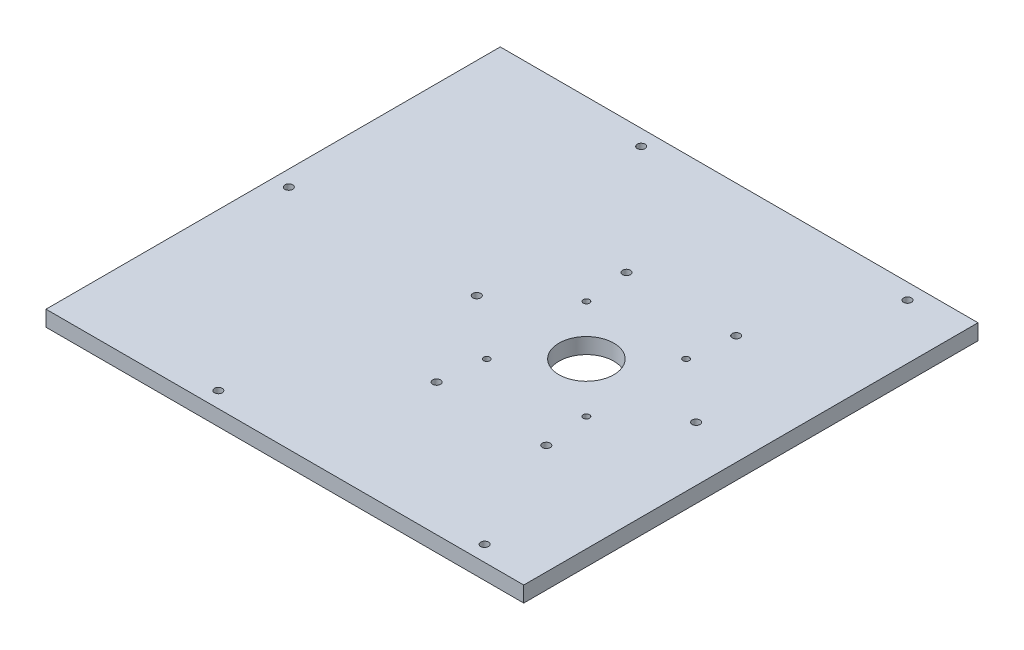
from build123d import *

# Parameters (mm, degrees)
SKETCH1_W           = 305
SKETCH1_H           = 290
SKETCH1_R           = 17.5
SKETCH1_R_2         = 2.5
SKETCH1_R_3         = 2
BOSS_EXTRUDE1_DEPTH = 10


with BuildPart() as part:
    # Sketch1 → Boss-Extrude1 (new body)
    with BuildSketch(Plane(origin=(0, 0, 0), x_dir=(1, 0, 0), z_dir=(0, 1, 0))):
        with Locations((-22.5, 0)):
            Rectangle(SKETCH1_W, SKETCH1_H)
        with Locations((25, 0)):
            Circle(SKETCH1_R, mode=Mode.SUBTRACT)
        with Locations((95, 0)):
            Circle(SKETCH1_R_2, mode=Mode.SUBTRACT)
        with Locations((56.819805153, 31.819805153)):
            Circle(SKETCH1_R_3, mode=Mode.SUBTRACT)
        with Locations((60, -60.621778265)):
            Circle(SKETCH1_R_2, mode=Mode.SUBTRACT)
        with Locations((-10, -60.621778265)):
            Circle(SKETCH1_R_2, mode=Mode.SUBTRACT)
        with Locations((-45, 0)):
            Circle(SKETCH1_R_2, mode=Mode.SUBTRACT)
        with Locations((56.819805153, -31.819805153)):
            Circle(SKETCH1_R_3, mode=Mode.SUBTRACT)
        with Locations((-6.819805153, -31.819805153)):
            Circle(SKETCH1_R_3, mode=Mode.SUBTRACT)
        with Locations((-6.819805153, 31.819805153)):
            Circle(SKETCH1_R_3, mode=Mode.SUBTRACT)
        with Locations((-165, 0)):
            Circle(SKETCH1_R_2, mode=Mode.SUBTRACT)
        with Locations((-75, -135)):
            Circle(SKETCH1_R_2, mode=Mode.SUBTRACT)
        with Locations((95, -135)):
            Circle(SKETCH1_R_2, mode=Mode.SUBTRACT)
        with Locations((95, 135)):
            Circle(SKETCH1_R_2, mode=Mode.SUBTRACT)
        with Locations((-75, 135)):
            Circle(SKETCH1_R_2, mode=Mode.SUBTRACT)
        with Locations((-10, 60.621778265)):
            Circle(SKETCH1_R_2, mode=Mode.SUBTRACT)
        with Locations((60, 60.621778265)):
            Circle(SKETCH1_R_2, mode=Mode.SUBTRACT)
    extrude(amount=BOSS_EXTRUDE1_DEPTH)


solid = part.part
